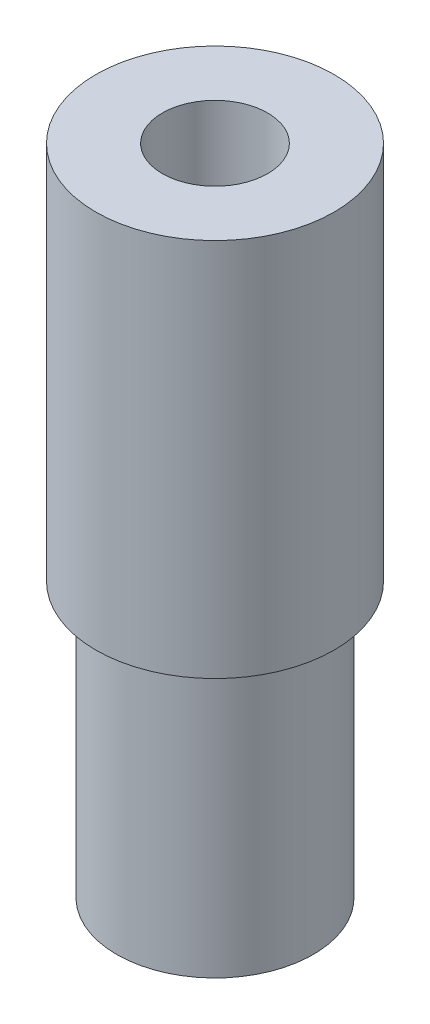
from build123d import *

# Parameters (mm, degrees)
SKETCH1_R           = 4.95
BOSS_EXTRUDE1_DEPTH = 13.8
SKETCH2_R           = 6
BOSS_EXTRUDE2_DEPTH = 19.1
SKETCH7_R           = 2.65
CUT_EXTRUDE1_DEPTH  = 33.9
CHAMFER1_SIZE       = 0.4


with BuildPart() as part:
    # Sketch1 → Boss-Extrude1 (new body)
    with BuildSketch(Plane(origin=(0, 0, 0), x_dir=(1, 0, 0), z_dir=(0, 1, 0))):
        Circle(SKETCH1_R)
    extrude(amount=BOSS_EXTRUDE1_DEPTH)

    # Sketch2 → Boss-Extrude2 (add)
    with BuildSketch(Plane(origin=(0, 13.8, 0), x_dir=(1, 0, 0), z_dir=(0, 1, 0))):
        Circle(SKETCH2_R)
    extrude(amount=BOSS_EXTRUDE2_DEPTH)

    # Sketch7 → Cut-Extrude1 (cut, through all)
    with BuildSketch(Plane(origin=(0, 0, 0), x_dir=(1, 0, 0), z_dir=(0, 1, 0))):
        Circle(SKETCH7_R)
    extrude(amount=CUT_EXTRUDE1_DEPTH, mode=Mode.SUBTRACT)

    # Chamfer1
    chamfer1_edges = [part.edges().sort_by_distance(p)[0] for p in [
        (-2.65, 0, 0),
    ]]
    chamfer(chamfer1_edges, length=CHAMFER1_SIZE)


solid = part.part
